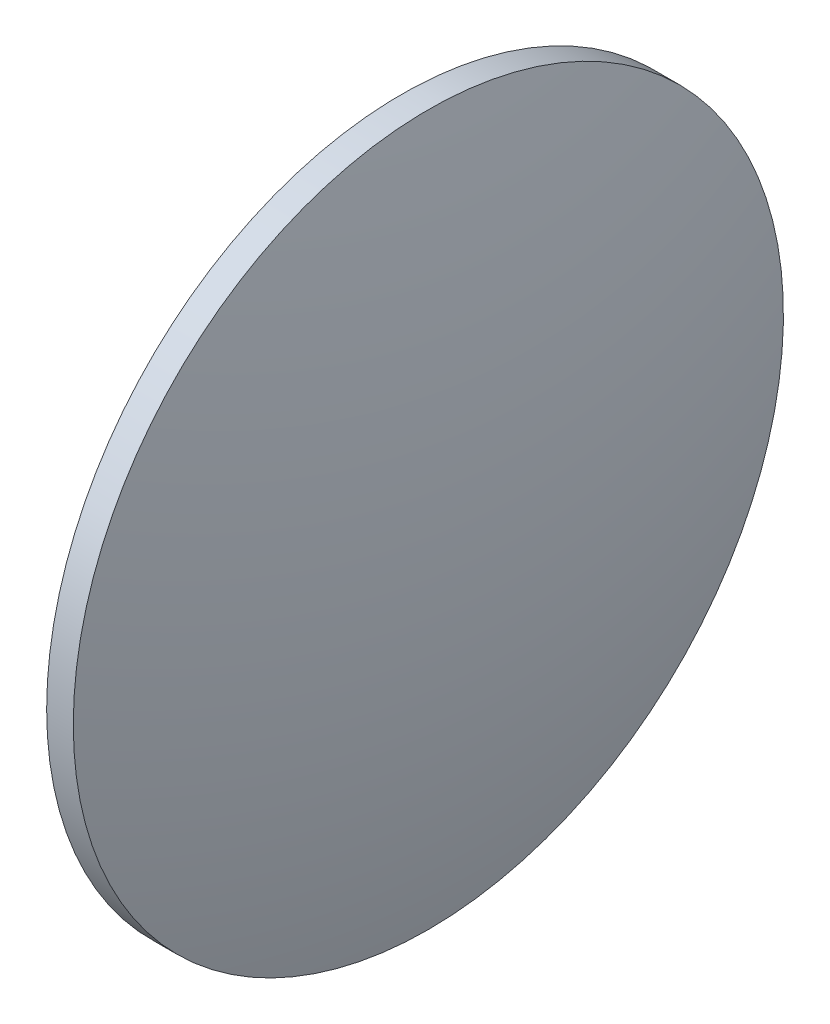
from build123d import *


with BuildPart() as part:
    # 草图1 → 旋转1 (revolve)
    with BuildSketch(Plane.XY, mode=Mode.PRIVATE) as revolve_1_sk:
        with BuildLine():
            Line((786.776833113, 121.191629626), (786.776833113, 161.191629626))
            Line((786.776833113, 161.191629626), (789.776833113, 161.191629626))
            ThreePointArc((789.776833113, 161.191629626), (793.708864911, 141.363171544), (795.027015348, 121.191629626))
            Line((795.027015348, 121.191629626), (786.776833113, 121.191629626))
        make_face()
    revolve(revolve_1_sk.sketch.rotate(Axis((767.951855436, 121.191629626, 0), (1, 0, 0)), 180), axis=Axis((767.951855436, 121.191629626, 0), (1, 0, 0)))  # turned: the seam where the file's is


solid = part.part
